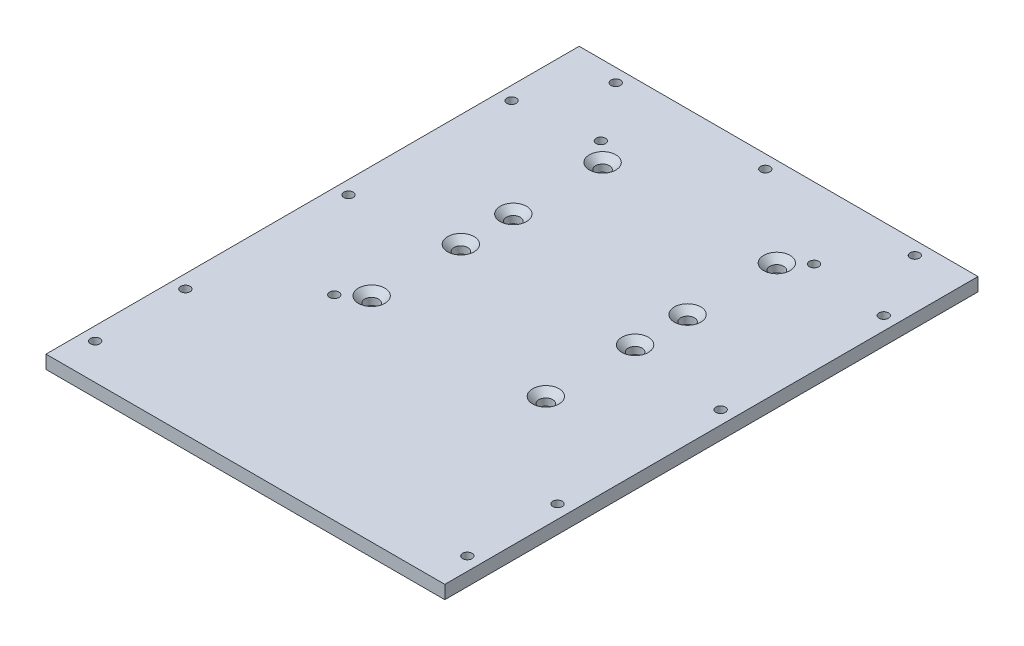
from build123d import *

# Parameters (mm, degrees)
SKETCH1_W                                    = 189.992
SKETCH1_H                                    = 254
BOSS_EXTRUDE1_DEPTH                          = 6.35
SKETCH3_R                                    = 2.2479
CUT_EXTRUDE1_DEPTH                           = 7.35
SKETCH4_R                                    = 2.2479
CUT_EXTRUDE2_DEPTH                           = 7.35
CSK_FOR_M6_COUNTERSUNK_FLAT_HEAD_SCR_2_COUNT = 2
CSK_FOR_M6_COUNTERSUNK_FLAT_HEAD_SCR_2_PITCH = 42.5196
CSK_FOR_M6_COUNTERSUNK_FLAT_HEAD_SCR_3_COUNT = 2
CSK_FOR_M6_COUNTERSUNK_FLAT_HEAD_SCR_3_PITCH = 24.9936
CSK_FOR_M6_COUNTERSUNK_FLAT_HEAD_SCR_4_COUNT = 2
CSK_FOR_M6_COUNTERSUNK_FLAT_HEAD_SCR_4_PITCH = 67.5132


with BuildPart() as part:
    # Sketch1 → Boss-Extrude1 (new body)
    with BuildSketch(Plane(origin=(0, 0, 0), x_dir=(1, 0, 0), z_dir=(0, 1, 0))):
        Rectangle(SKETCH1_W, SKETCH1_H)
    extrude(amount=BOSS_EXTRUDE1_DEPTH)

    # Sketch3 → Cut-Extrude1 (cut, through all)
    with BuildSketch(Plane(origin=(0, 6.35, 0), x_dir=(1, 0, 0), z_dir=(0, 1, 0))):
        with Locations((-88.646, -109.9312)):
            Circle(SKETCH3_R)
        with Locations((-88.646, -66.9544)):
            Circle(SKETCH3_R)
        with Locations((-88.646, 10.7442)):
            Circle(SKETCH3_R)
        with Locations((-88.646, 88.4428)):
            Circle(SKETCH3_R)
        with Locations((-50.8, 93.1164)):
            Circle(SKETCH3_R)
        with Locations((-71.247, 120.65)):
            Circle(SKETCH3_R)
        with Locations((0, 120.65)):
            Circle(SKETCH3_R)
    cut_extrude1 = extrude(amount=-CUT_EXTRUDE1_DEPTH, mode=Mode.SUBTRACT)

    # Mirror1: Cut-Extrude1 across plane
    add(cut_extrude1.mirror(Plane(origin=(0, 0, 0), x_dir=(0, 0, 1), z_dir=(1, 0, 0))), mode=Mode.SUBTRACT)

    # Sketch4 → Cut-Extrude2 (cut, through all)
    with BuildSketch(Plane(origin=(0, 6.35, 0), x_dir=(1, 0, 0), z_dir=(0, 1, 0))):
        with Locations((-50.8, -33.8836)):
            Circle(SKETCH4_R)
    extrude(amount=-CUT_EXTRUDE2_DEPTH, mode=Mode.SUBTRACT)

    # Sketch7 → CSK for M6 Countersunk Flat Head Screw1 (revolve, cut)
    with BuildSketch(Plane(origin=(-41.5036, 6.35, -17.145), x_dir=(0, 0, 1), z_dir=(1, 0, 0))):
        Polygon((0, 0), (0, 46.984041764), (3.302, 45), (3.302, 2.9972), (6.2992, 0), align=None)
    csk_for_m6_countersunk_flat_head_screw1 = revolve(axis=Axis((-41.5036, 12.7, -17.145), (0, -1, 0)), mode=Mode.SUBTRACT)

    # CSK for M6 Countersunk Flat Head Scr 2: CSK for M6 Countersunk Flat Head Screw1 ×2
    with Locations(*[(0, 0, i * CSK_FOR_M6_COUNTERSUNK_FLAT_HEAD_SCR_2_PITCH) for i in range(1, CSK_FOR_M6_COUNTERSUNK_FLAT_HEAD_SCR_2_COUNT)]):
        add(csk_for_m6_countersunk_flat_head_screw1, mode=Mode.SUBTRACT)

    # CSK for M6 Countersunk Flat Head Scr 3: CSK for M6 Countersunk Flat Head Screw1 ×2
    with Locations(*[(0, 0, -i * CSK_FOR_M6_COUNTERSUNK_FLAT_HEAD_SCR_3_PITCH) for i in range(1, CSK_FOR_M6_COUNTERSUNK_FLAT_HEAD_SCR_3_COUNT)]):
        add(csk_for_m6_countersunk_flat_head_screw1, mode=Mode.SUBTRACT)

    # CSK for M6 Countersunk Flat Head Scr 4: CSK for M6 Countersunk Flat Head Screw1 ×2
    with Locations(*[(0, 0, -i * CSK_FOR_M6_COUNTERSUNK_FLAT_HEAD_SCR_4_PITCH) for i in range(1, CSK_FOR_M6_COUNTERSUNK_FLAT_HEAD_SCR_4_COUNT)]):
        add(csk_for_m6_countersunk_flat_head_screw1, mode=Mode.SUBTRACT)

    # Mirror2: CSK for M6 Countersunk Flat Head Screw1 across plane
    add(csk_for_m6_countersunk_flat_head_screw1.mirror(Plane(origin=(0, 0, 0), x_dir=(0, 0, 1), z_dir=(1, 0, 0))), mode=Mode.SUBTRACT)

    # Mirror2 copy 1 sketch → Mirror2 copy 1 (revolve, cut)
    with BuildSketch(Plane(origin=(41.5036, 6.35, 25.3746), x_dir=(0, 0, 1), z_dir=(-1, 0, 0))):
        Polygon((0, 0), (0, -46.984041764), (3.302, -45), (3.302, -2.9972), (6.2992, 0), align=None)
    revolve(axis=Axis((41.5036, 12.7, 25.3746), (0, 1, 0)), mode=Mode.SUBTRACT)

    # Mirror2 copy 2 sketch → Mirror2 copy 2 (revolve, cut)
    with BuildSketch(Plane(origin=(41.5036, 6.35, -42.1386), x_dir=(0, 0, 1), z_dir=(-1, 0, 0))):
        Polygon((0, 0), (0, -46.984041764), (3.302, -45), (3.302, -2.9972), (6.2992, 0), align=None)
    revolve(axis=Axis((41.5036, 12.7, -42.1386), (0, 1, 0)), mode=Mode.SUBTRACT)

    # Mirror2 copy 3 sketch → Mirror2 copy 3 (revolve, cut)
    with BuildSketch(Plane(origin=(41.5036, 6.35, -84.6582), x_dir=(0, 0, 1), z_dir=(-1, 0, 0))):
        Polygon((0, 0), (0, -46.984041764), (3.302, -45), (3.302, -2.9972), (6.2992, 0), align=None)
    revolve(axis=Axis((41.5036, 12.7, -84.6582), (0, 1, 0)), mode=Mode.SUBTRACT)


solid = part.part
